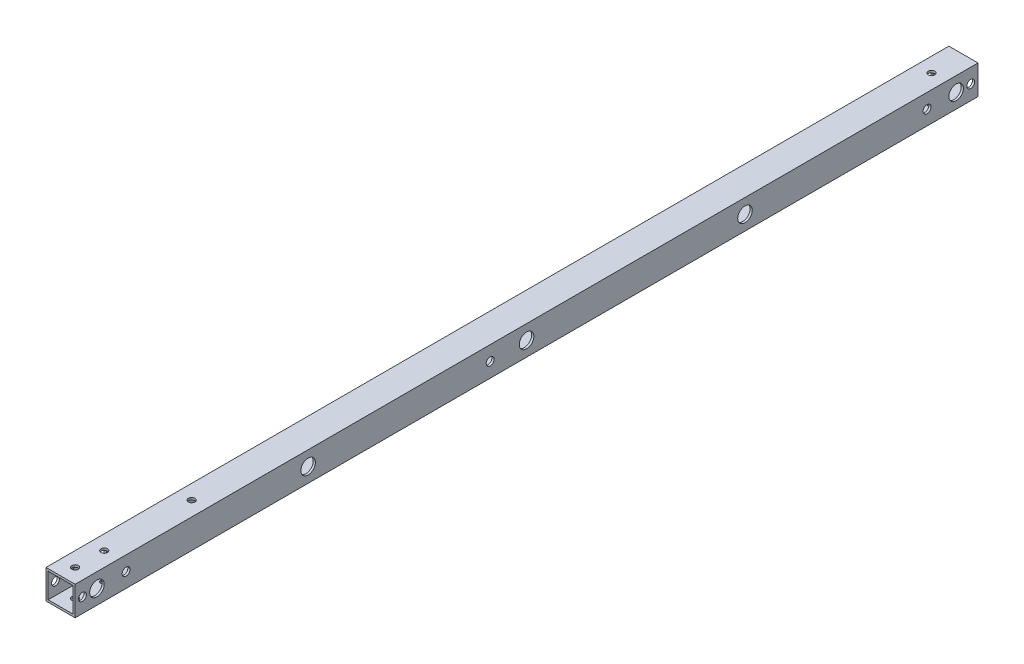
from build123d import *

# Parameters (mm, degrees)
SKETCH_1_W                  = 20
SKETCH_1_H                  = 20
SKETCH_1_W_2                = 17
SKETCH_1_H_2                = 17
EXTRUDE_1_DEPTH             = 620
SKETCH_2_R                  = 2.7
CUT_EXTRUDE_1_DEPTH         = 25
SKETCH_3_R                  = 2.25
CUT_EXTRUDE_2_DEPTH         = 25
SKETCH_4_R                  = 2.7
CUT_EXTRUDE_3_DEPTH         = 40
SKETCH_6_R                  = 5
CUT_EXTRUDE_4_DEPTH         = 10
SKETCH_7_R                  = 5
CUT_EXTRUDE_5_DEPTH         = 10
SKETCH_8_R                  = 5
CUT_EXTRUDE_6_DEPTH         = 5
HOLE_WIZARD_4_3_4_3_1_D     = 4.3
HOLE_WIZARD_10_0_10_1_D     = 10
HOLE_WIZARD_10_0_10_1_DEPTH = 1.5


with BuildPart() as part:
    # ｽｹｯﾁ1 → ﾎﾞｽ - 押し出し1 (new body)
    with BuildSketch(Plane.XY):
        Rectangle(SKETCH_1_W, SKETCH_1_H)
        Rectangle(SKETCH_1_W_2, SKETCH_1_H_2, mode=Mode.SUBTRACT)
    extrude(amount=EXTRUDE_1_DEPTH)

    # ｽｹｯﾁ2 → ｶｯﾄ - 押し出し1 (cut)
    with BuildSketch(Plane(origin=(10, 0, 0), x_dir=(0, 0, -1), z_dir=(1, 0, 0))):
        with Locations((-585, 0)):
            Circle(SKETCH_2_R)
        with Locations((-35, 0)):
            Circle(SKETCH_2_R)
        with Locations((-335, 0)):
            Circle(SKETCH_2_R)
    extrude(amount=-CUT_EXTRUDE_1_DEPTH, mode=Mode.SUBTRACT)

    # ｽｹｯﾁ3 → ｶｯﾄ - 押し出し2 (cut)
    with BuildSketch(Plane(origin=(0, 10, 0), x_dir=(1, 0, 0), z_dir=(0, 1, 0))):
        with Locations((0, -22)):
            Circle(SKETCH_3_R)
        with Locations((0, -610)):
            Circle(SKETCH_3_R)
        with Locations((0, -530)):
            Circle(SKETCH_3_R)
        with Locations((0, -590)):
            Circle(SKETCH_3_R)
    extrude(amount=-CUT_EXTRUDE_2_DEPTH, mode=Mode.SUBTRACT)

    # ｽｹｯﾁ4 → ｶｯﾄ - 押し出し3 (cut)
    with BuildSketch(Plane(origin=(10, 0, 0), x_dir=(0, 0, -1), z_dir=(1, 0, 0))):
        with Locations((-15, 0)):
            Circle(SKETCH_4_R)
        with Locations((-5, 0)):
            Circle(SKETCH_4_R)
        with Locations((-615, 0)):
            Circle(SKETCH_4_R)
        with Locations((-605, 0)):
            Circle(SKETCH_4_R)
    extrude(amount=-CUT_EXTRUDE_3_DEPTH, mode=Mode.SUBTRACT)

    # ｽｹｯﾁ6 → ｶｯﾄ - 押し出し4 (cut)
    with BuildSketch(Plane(origin=(0, -10, 0), x_dir=(-1, 0, 0), z_dir=(0, -1, 0))):
        with Locations((0, -530)):
            Circle(SKETCH_6_R)
    extrude(amount=-CUT_EXTRUDE_4_DEPTH, mode=Mode.SUBTRACT)

    # ｽｹｯﾁ7 → ｶｯﾄ - 押し出し5 (cut)
    with BuildSketch(Plane(origin=(-10, 0, 0), x_dir=(0, 0, -1), z_dir=(1, 0, 0))):
        with Locations((-585, 0)):
            Circle(SKETCH_7_R)
        with Locations((-335, 0)):
            Circle(SKETCH_7_R)
        with Locations((-35, 0)):
            Circle(SKETCH_7_R)
    extrude(amount=CUT_EXTRUDE_5_DEPTH, mode=Mode.SUBTRACT)

    # ｽｹｯﾁ8 → ｶｯﾄ - 押し出し6 (cut)
    with BuildSketch(Plane(origin=(10, 0, 0), x_dir=(0, 0, -1), z_dir=(1, 0, 0))):
        with Locations((-605, 0)):
            Circle(SKETCH_8_R)
        with Locations((-15, 0)):
            Circle(SKETCH_8_R)
    extrude(amount=-CUT_EXTRUDE_6_DEPTH, mode=Mode.SUBTRACT)

    # Ø4.3 (4.3) 直径の穴1 (through all)
    with Locations(Plane(origin=(-10, 0, 0), x_dir=(0, 0, -1), z_dir=(-1, 0, 0))):
        with Locations((-460, 0), (-310, 0), (-160, 0)):
            Hole(HOLE_WIZARD_4_3_4_3_1_D / 2)

    # Ø10.0 (10) 直径の穴1
    with Locations(Plane(origin=(10, 0, 0), x_dir=(0, 0, -1), z_dir=(1, 0, 0))):
        with Locations((-460, 0), (-310, 0), (-160, 0)):
            Hole(HOLE_WIZARD_10_0_10_1_D / 2, depth=HOLE_WIZARD_10_0_10_1_DEPTH)


solid = part.part
